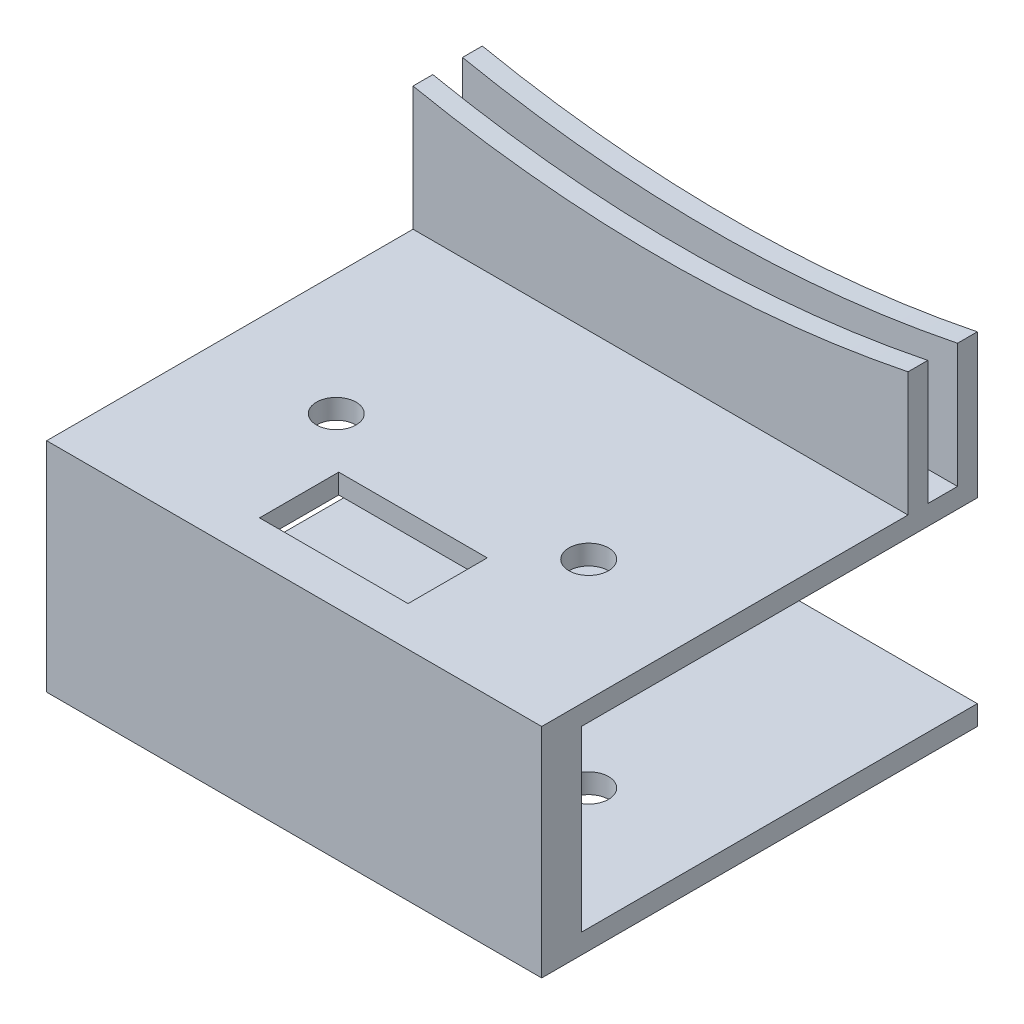
from build123d import *

# Parameters (mm, degrees)
SKETCH_1_W          = 50
SKETCH_1_H          = 44
EXTRUDE_1_DEPTH     = 22
SKETCH_2_W          = 50
SKETCH_2_H          = 2
EXTRUDE_2_DEPTH     = 20
SKETCH_3_W          = 40
SKETCH_3_H          = 18
CUT_EXTRUDE_1_DEPTH = 50
SKETCH_4_R          = 2
CUT_EXTRUDE_2_DEPTH = 22
SKETCH_5_W          = 15
SKETCH_5_H          = 8
CUT_EXTRUDE_3_DEPTH = 2
CUT_EXTRUDE_4_DEPTH = 7


with BuildPart() as part:
    # 스케치1 → 보스-돌출1 (new body)
    with BuildSketch(Plane(origin=(0, 0, 0), x_dir=(1, 0, 0), z_dir=(0, 1, 0))):
        Rectangle(SKETCH_1_W, SKETCH_1_H)
    extrude(amount=EXTRUDE_1_DEPTH)

    # 스케치2 → 보스-돌출2 (add)
    with BuildSketch(Plane(origin=(0, 22, 0), x_dir=(1, 0, 0), z_dir=(0, 1, 0))):
        with Locations((0, 21)):
            Rectangle(SKETCH_2_W, SKETCH_2_H)
        with Locations((0, 16)):
            Rectangle(SKETCH_2_W, SKETCH_2_H)
    extrude(amount=EXTRUDE_2_DEPTH)

    # 스케치3 → 컷-돌출1 (cut)
    with BuildSketch(Plane(origin=(25, 0, 0), x_dir=(0, 0, -1), z_dir=(1, 0, 0))):
        with Locations((2, 11)):
            Rectangle(SKETCH_3_W, SKETCH_3_H)
    extrude(amount=-CUT_EXTRUDE_1_DEPTH, mode=Mode.SUBTRACT)

    # 스케치4 → 컷-돌출2 (cut)
    with BuildSketch(Plane.XZ):
        with Locations((12.75, 5)):
            Circle(SKETCH_4_R)
        with Locations((-12.75, 5)):
            Circle(SKETCH_4_R)
    extrude(amount=-CUT_EXTRUDE_2_DEPTH, mode=Mode.SUBTRACT)

    # 스케치5 → 컷-돌출3 (cut)
    with BuildSketch(Plane(origin=(0, 22, 0), x_dir=(1, 0, 0), z_dir=(0, 1, 0))):
        with Locations((0, -14)):
            Rectangle(SKETCH_5_W, SKETCH_5_H)
    extrude(amount=-CUT_EXTRUDE_3_DEPTH, mode=Mode.SUBTRACT)

    # 스케치7 → 컷-돌출4 (cut)
    with BuildSketch(Plane(origin=(0, 0, -22), x_dir=(-1, 0, 0), z_dir=(0, 0, -1))):
        with BuildLine():
            Line((25, 34.525512861), (25, 42))
            Line((25, 42), (-25, 42))
            Line((-25, 42), (-25, 34.525512861))
            ThreePointArc((-25, 34.525512861), (0, 32), (25, 34.525512861))
        make_face()
    extrude(amount=-CUT_EXTRUDE_4_DEPTH, mode=Mode.SUBTRACT)


solid = part.part
